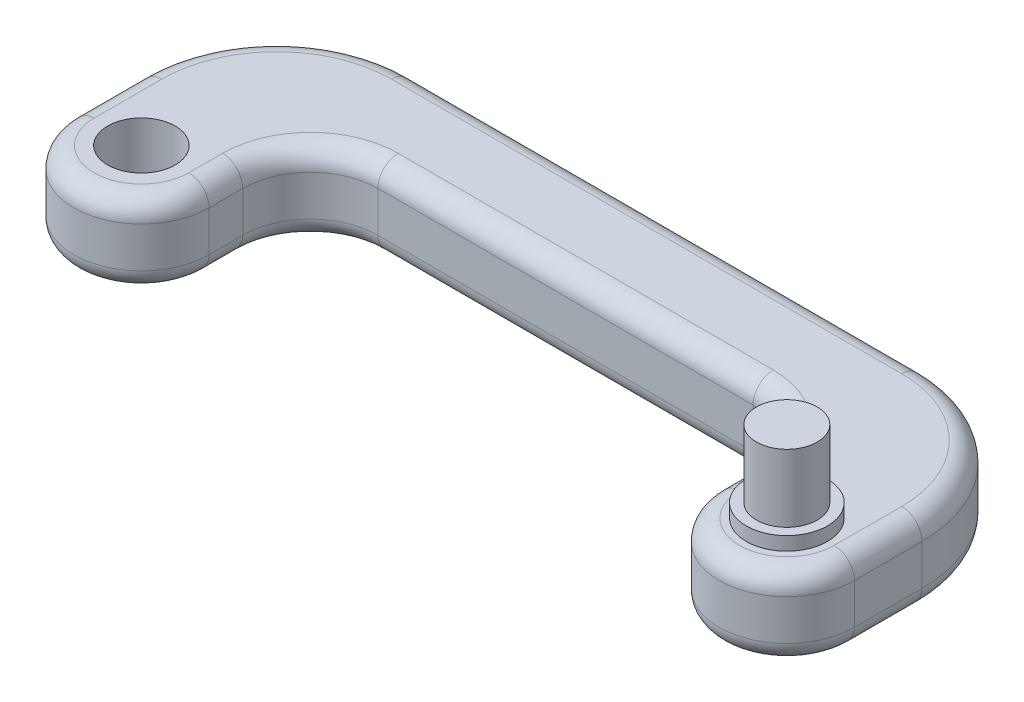
from build123d import *

# Parameters (mm, degrees)
SKETCH7_R           = 5
BOSS_EXTRUDE5_DEPTH = 12
SKETCH8_R           = 6
BOSS_EXTRUDE6_DEPTH = 2
SKETCH9_R           = 4.5
BOSS_EXTRUDE7_DEPTH = 10
FILLET2_R           = 20
FILLET3_R           = 10
FILLET5_R           = 3


with BuildPart() as part:
    # Sketch7 → Boss-Extrude5 (new body)
    with BuildSketch(Plane(origin=(0, 0, 0), x_dir=(1, 0, 0), z_dir=(0, 1, 0))):
        with BuildLine():
            Line((-105.5, 30), (-105.5, 0))
            ThreePointArc((-105.5, 0), (-95.5, -10), (-85.5, 0))
            Line((-85.5, 0), (-85.5, 15))
            Line((-85.5, 15), (-10, 15))
            Line((-10, 15), (-10, 0))
            ThreePointArc((-10, 0), (0, -10), (10, 0))
            Line((10, 0), (10, 30))
            Line((10, 30), (-10, 30))
            Line((-10, 30), (-85.5, 30))
            Line((-85.5, 30), (-105.5, 30))
        make_face()
        with Locations((-95.5, 0)):
            Circle(SKETCH7_R, mode=Mode.SUBTRACT)
    extrude(amount=BOSS_EXTRUDE5_DEPTH)

    # Sketch8 → Boss-Extrude6 (add)
    with BuildSketch(Plane(origin=(0, 12, 0), x_dir=(1, 0, 0), z_dir=(0, 1, 0))):
        Circle(SKETCH8_R)
    extrude(amount=BOSS_EXTRUDE6_DEPTH)

    # Sketch9 → Boss-Extrude7 (add)
    with BuildSketch(Plane(origin=(0, 14, 0), x_dir=(1, 0, 0), z_dir=(0, 1, 0))):
        Circle(SKETCH9_R)
    extrude(amount=BOSS_EXTRUDE7_DEPTH)

    # Fillet2
    fillet2_edges = [part.edges().sort_by_distance(p)[0] for p in [
        (-105.5, 6, -30),
        (10, 6, -30),
    ]]
    fillet(fillet2_edges, radius=FILLET2_R)

    # Fillet3
    fillet3_edges = [part.edges().sort_by_distance(p)[0] for p in [
        (-10, 6, -15),
        (-85.5, 6, -15),
    ]]
    fillet(fillet3_edges, radius=FILLET3_R)

    # Fillet5
    fillet5_edges = [part.edges().sort_by_distance(p)[0] for p in [
        (10, 0, -5),
        (-105.5, 12, -5),
        (0, 0, 10),
        (-10, 0, -2.5),
        (-85.5, 0, -2.5),
        (-95.5, 0, 10),
        (-105.5, 0, -5),
        (-95.5, 12, 10),
        (-85.5, 12, -2.5),
        (-10, 12, -2.5),
        (0, 12, 10),
        (-47.75, 0, -30),
        (-47.75, 12, -30),
        (-99.642135624, 0, -24.142135624),
        (10, 12, -5),
        (4.142135624, 0, -24.142135624),
        (-99.642135624, 12, -24.142135624),
        (4.142135624, 12, -24.142135624),
        (-47.75, 0, -15),
        (-47.75, 12, -15),
        (-12.928932188, 0, -12.071067812),
        (-12.928932188, 12, -12.071067812),
        (-82.571067812, 0, -12.071067812),
        (-82.571067812, 12, -12.071067812),
    ]]
    fillet(fillet5_edges, radius=FILLET5_R)


solid = part.part
